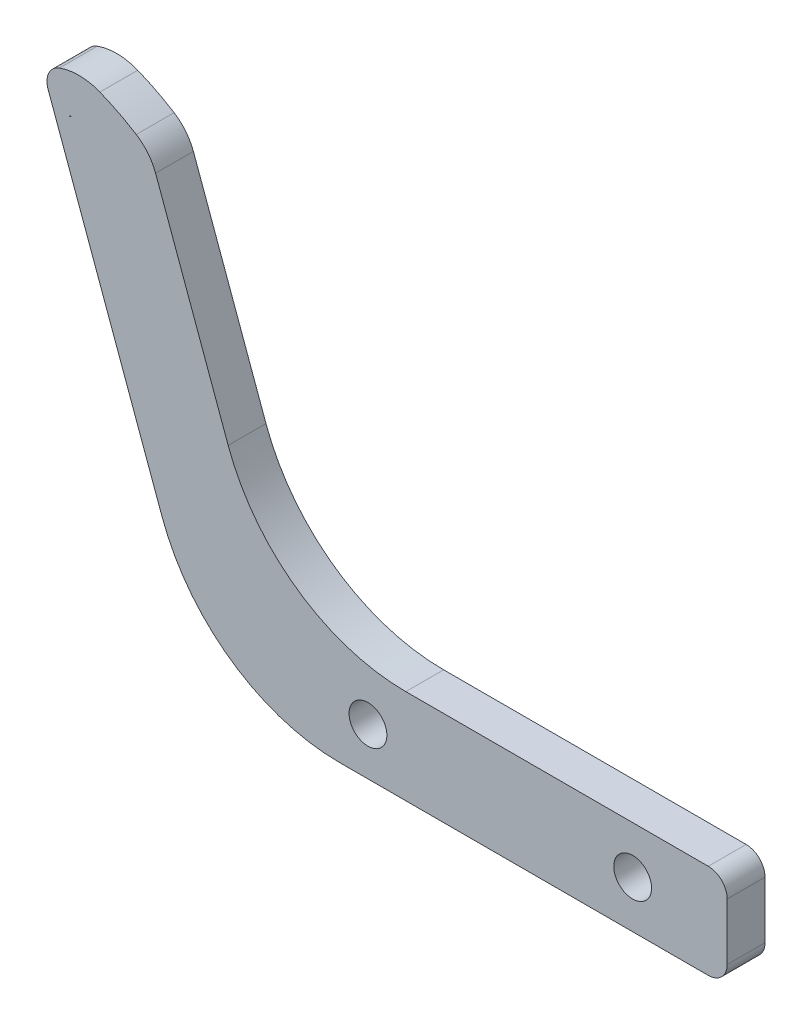
from build123d import *

# Parameters (mm, degrees)
SKETCH_1_W      = 50
SKETCH_1_H      = 10
SKETCH_1_R      = 2
SKETCH_1_W_2    = 5
EXTRUDE_1_DEPTH = 4
FILLET_1_R      = 20
FILLET_2_R      = 20
FILLET_3_R      = 2
EXTRUDE_2_DEPTH = 4


with BuildPart() as part:
    # 草图1 → 凸台-拉伸1 (new body)
    with BuildSketch(Plane.XY):
        Polygon((-49.968629634, 37.889241728), (-61.844641091, 41.280271037), (-45, -5), (-45, 5), (-37.997924618, 5), align=None)
        with Locations((-20, 0)):
            Rectangle(SKETCH_1_W, SKETCH_1_H)
        with Locations((-28, 0)):
            Circle(SKETCH_1_R, mode=Mode.SUBTRACT)
        Circle(SKETCH_1_R, mode=Mode.SUBTRACT)
        with Locations((7.5, 0)):
            Rectangle(SKETCH_1_W_2, SKETCH_1_H)
    extrude(amount=EXTRUDE_1_DEPTH)

    # 圆角1
    fillet_1_edges = [part.edges().sort_by_distance(p)[0] for p in [
        (-37.997924618, 5, 2),
        (-45, -5, 2),
    ]]
    fillet(fillet_1_edges, radius=FILLET_1_R)

    # 圆角2
    fillet_2_edges = [part.edges().sort_by_distance(p)[0] for p in [
        (-49.968629634, 37.889241728, 2),
    ]]
    fillet(fillet_2_edges, radius=FILLET_2_R)

    # 圆角3
    fillet_3_edges = [part.edges().sort_by_distance(p)[0] for p in [
        (-61.844641091, 41.280271037, 2),
        (10, -5, 2),
        (10, 5, 2),
    ]]
    fillet(fillet_3_edges, radius=FILLET_3_R)

    # 草图2 → 凸台-拉伸2 (add)
    with BuildSketch(Plane.XY.offset(4)):
        with BuildLine():
            ThreePointArc((-56.355465994, 43.741712807), (-58.489892138, 44.170450367), (-60.636797067, 43.809354689))
            ThreePointArc((-60.636797067, 43.809354689), (-61.765372114, 42.775205935), (-61.832141712, 41.245929274))
            Line((-61.832141712, 41.245929274), (-60.464061138, 37.487158791))
            ThreePointArc((-60.464061138, 37.487158791), (-60.461686369, 38.861729082), (-59.572682652, 39.910119045))
            ThreePointArc((-59.572682652, 39.910119045), (-59.555544901, 39.941826673), (-59.538179031, 39.973409941))
            ThreePointArc((-59.538179031, 39.973409941), (-59.402093878, 40.007270752), (-59.26871602, 40.050584379))
            ThreePointArc((-59.26871602, 40.050584379), (-58.553081169, 40.170949505), (-57.841605929, 40.028036987))
            ThreePointArc((-57.841605929, 40.028036987), (-50.908526864, 35.37662093), (-46.47845319, 28.300060756))
            Line((-46.47845319, 28.300060756), (-50.467059195, 39.258665691))
            ThreePointArc((-50.467059195, 39.258665691), (-51.276051122, 40.690541098), (-52.50584262, 41.782487979))
            ThreePointArc((-52.50584262, 41.782487979), (-54.386487154, 42.848883136), (-56.355465994, 43.741712807))
        make_face()
    extrude(amount=-EXTRUDE_2_DEPTH)


solid = part.part
